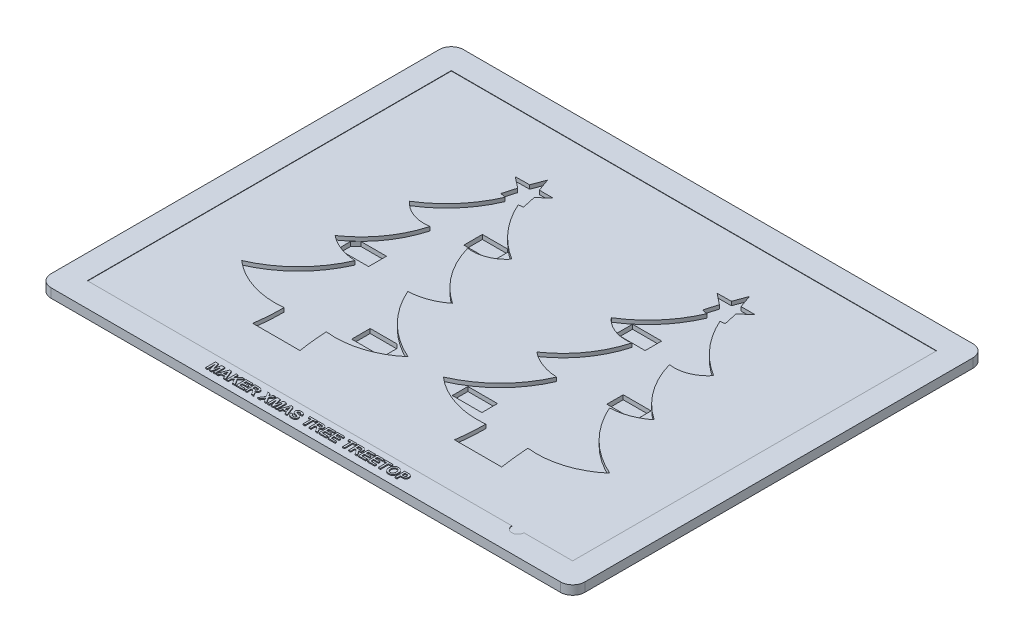
from build123d import *

# Parameters (mm, degrees)
BOSS_EXTRUDE1_DEPTH = 3.75
CUT_EXTRUDE1_DEPTH  = 0.15
BOSS_EXTRUDE2_DEPTH = 0.4
CUT_EXTRUDE3_DEPTH  = 1.6
SKETCH10_W          = 12.19588201
SKETCH10_H          = 6.447360915
SKETCH10_W_2        = 11.52373803
SKETCH10_H_2        = 6.728235922
SKETCH10_W_3        = 12.009681744
SKETCH10_H_3        = 6.810698755
CUT_EXTRUDE4_DEPTH  = 1.8


with BuildPart() as part:
    # Sketch1 → Boss-Extrude1 (new body)
    with BuildSketch(Plane(origin=(0, 0, 0), x_dir=(1, 0, 0), z_dir=(0, 1, 0))):
        with BuildLine():
            Line((-105, 85), (105, 85))
            ThreePointArc((105, 85), (108.535533906, 83.535533906), (110, 80))
            Line((110, 80), (110, -80))
            ThreePointArc((110, -80), (108.535533906, -83.535533906), (105, -85))
            Line((105, -85), (-105, -85))
            ThreePointArc((-105, -85), (-108.535533906, -83.535533906), (-110, -80))
            Line((-110, -80), (-110, 80))
            ThreePointArc((-110, 80), (-108.535533906, 83.535533906), (-105, 85))
        make_face()
    extrude(amount=BOSS_EXTRUDE1_DEPTH)

    # Sketch2 → Cut-Extrude1 (cut)
    with BuildSketch(Plane(origin=(0, 3.75, 0), x_dir=(1, 0, 0), z_dir=(0, 1, 0))):
        with BuildLine():
            Line((79.947940252, -75), (100, -75))
            Line((100, -75), (100, 75))
            Line((100, 75), (-100, 75))
            Line((-100, 75), (-100, -75))
            Line((-100, -75), (74.947940252, -75))
            ThreePointArc((74.947940252, -75), (77.447940252, -77.5), (79.947940252, -75))
        make_face()
    extrude(amount=-CUT_EXTRUDE1_DEPTH, mode=Mode.SUBTRACT)

    # Sketch5 → Boss-Extrude2 (add)
    with BuildSketch(Plane(origin=(0, 3.75, 0), x_dir=(1, 0, 0), z_dir=(0, 1, 0))):
        Polygon((-44.228593173, -82), (-44.228593173, -78), (-42.927311122, -78), (-42.254234199, -80.728365385), (-41.581157276, -78), (-40.279875224, -78), (-40.279875224, -82), (-41.049105994, -82), (-41.074747019, -78.850961538), (-41.825548301, -82), (-42.682920096, -82), (-43.433721378, -78.850961538), (-43.459362404, -82), align=None)
        Polygon((-36.074747019, -82), (-36.890452147, -82), (-37.227791891, -81.076923077), (-38.763048301, -81.076923077), (-39.100388045, -82), (-39.920900865, -82), (-38.408881635, -78), (-37.593977788, -78), align=None)
        Polygon((-37.472182917, -80.41025641), (-37.997823942, -78.974358974), (-38.521862404, -80.41025641), align=None, mode=Mode.SUBTRACT)
        Polygon((-35.664490609, -82), (-35.664490609, -78), (-34.89525984, -78), (-34.89525984, -79.790865385), (-33.208561122, -78), (-32.151670096, -78), (-33.670900865, -79.546474359), (-32.100388045, -82), (-33.125227788, -82), (-34.254234199, -80.141826923), (-34.89525984, -80.794070513), (-34.89525984, -82), align=None)
        Polygon((-31.664490609, -82), (-31.664490609, -78), (-28.690131635, -78), (-28.690131635, -78.666666667), (-30.89525984, -78.666666667), (-30.89525984, -79.538461538), (-28.843977788, -79.538461538), (-28.843977788, -80.205128205), (-30.89525984, -80.205128205), (-30.89525984, -81.333333333), (-28.638849583, -81.333333333), (-28.638849583, -82), align=None)
        with BuildLine():
            Line((-27.972182917, -82), (-27.972182917, -78))
            Line((-27.972182917, -78), (-26.293497019, -78))
            add(Edge.make_bspline(
                [(-26.293497019, -78), (-26.242480096, -78.000314416), (-26.144161146, -78.000920354), (-26.001972765, -78.005338971), (-25.87084316, -78.01459623), (-25.750190639, -78.025080153), (-25.640594706, -78.040333585), (-25.541622037, -78.058607046), (-25.453439261, -78.079783469), (-25.374759738, -78.105145668), (-25.303019997, -78.134173587), (-25.236190907, -78.168724977), (-25.173537666, -78.209206177), (-25.114097978, -78.254221912), (-25.057620142, -78.303841349), (-25.00565248, -78.359377664), (-24.957289577, -78.420003904), (-24.912570457, -78.485215655), (-24.87317571, -78.554724967), (-24.837179255, -78.626299533), (-24.807876783, -78.700701015), (-24.783673207, -78.777578925), (-24.764339018, -78.856766352), (-24.750919457, -78.938464618), (-24.742541769, -79.022525849), (-24.741793892, -79.079306772), (-24.741413686, -79.108173077)],
                knots=[0, 0, 0, 0, 0.000153053, 0.000294962, 0.000426667, 0.000547382, 0.000658208, 0.000758474, 0.000849231, 0.000930066, 0.001006251, 0.001081152, 0.001155391, 0.001229751, 0.001304678, 0.001380635, 0.001457596, 0.001537161, 0.001617565, 0.001697119, 0.001777319, 0.001857146, 0.001938771, 0.002021629, 0.002105347, 0.002191918, 0.002191918, 0.002191918, 0.002191918], degree=3))
            add(Edge.make_bspline(
                [(-24.741413686, -79.108173077), (-24.742118911, -79.144536541), (-24.743497116, -79.215600774), (-24.756180082, -79.319758822), (-24.775017527, -79.419274402), (-24.801870159, -79.514285384), (-24.838791982, -79.603674303), (-24.881653705, -79.688693371), (-24.93277351, -79.7690542), (-24.991804094, -79.843960137), (-25.058692609, -79.913477489), (-25.133732186, -79.976175641), (-25.216387067, -80.032299633), (-25.307157264, -80.08152582), (-25.405410737, -80.123608876), (-25.511573547, -80.159016277), (-25.625165094, -80.187833956), (-25.704179311, -80.201393536), (-25.744618814, -80.208333333)],
                knots=[0, 0, 0, 0, 0.000109048, 0.00021311, 0.000314313, 0.000412711, 0.000508684, 0.000604006, 0.000698033, 0.000793893, 0.000889662, 0.000986921, 0.001086709, 0.0011889, 0.001296218, 0.001406949, 0.00152433, 0.001647386, 0.001647386, 0.001647386, 0.001647386], degree=3))
            add(Edge.make_bspline(
                [(-25.744618814, -80.208333333), (-25.705509273, -80.23423595), (-25.628966574, -80.2849309), (-25.52306424, -80.368426117), (-25.427989071, -80.456060805), (-25.356002949, -80.533991022), (-25.300689034, -80.602522275), (-25.25615188, -80.662460371), (-25.208111421, -80.731440424), (-25.157038828, -80.80949981), (-25.101424265, -80.89594789), (-25.043336138, -80.992107883), (-24.981558871, -81.09704183), (-24.94002345, -81.170343505), (-24.918497019, -81.208333333)],
                knots=[0, 0, 0, 0, 0.000140684, 0.000275337, 0.000404055, 0.000528243, 0.000593191, 0.000668192, 0.000752216, 0.000845333, 0.000948026, 0.001060574, 0.001182332, 0.001313324, 0.001313324, 0.001313324, 0.001313324], degree=3))
            Line((-24.918497019, -81.208333333), (-24.433721378, -82))
            Line((-24.433721378, -82), (-25.33275984, -82))
            Line((-25.33275984, -82), (-25.901670096, -81.092147436))
            add(Edge.make_bspline(
                [(-25.901670096, -81.092147436), (-25.927797847, -81.055788596), (-25.977681094, -80.986372096), (-26.049690643, -80.887728996), (-26.11557299, -80.799918919), (-26.173574786, -80.721669989), (-26.226630895, -80.655200746), (-26.273130325, -80.599352861), (-26.312125941, -80.552927919), (-26.356249578, -80.506895587), (-26.407582745, -80.45958717), (-26.471129106, -80.413718968), (-26.536385323, -80.377153321), (-26.606302146, -80.349252873), (-26.68715884, -80.329798827), (-26.784361391, -80.317404127), (-26.900966074, -80.308259456), (-26.9852479, -80.307890941), (-27.030676506, -80.307692308)],
                knots=[0, 0, 0, 0, 0.000134319, 0.000256443, 0.00036638, 0.000463655, 0.000548625, 0.000621467, 0.000681697, 0.000730437, 0.000812688, 0.000890746, 0.000964994, 0.001036564, 0.001115854, 0.001213762, 0.001330282, 0.001466521, 0.001466521, 0.001466521, 0.001466521], degree=3))
            Line((-27.030676506, -80.307692308), (-27.202952147, -80.307692308))
            Line((-27.202952147, -80.307692308), (-27.202952147, -82))
            Line((-27.202952147, -82), (-27.972182917, -82))
        make_face()
        with BuildLine():
            Line((-27.202952147, -79.641025641), (-26.583561122, -79.641025641))
            add(Edge.make_bspline(
                [(-26.583561122, -79.641025641), (-26.535748984, -79.640923177), (-26.444658783, -79.640727965), (-26.315126705, -79.6379004), (-26.199410943, -79.635500482), (-26.098203968, -79.629470586), (-26.011052973, -79.623494391), (-25.938307564, -79.615727506), (-25.879354841, -79.606547299), (-25.820470979, -79.592274486), (-25.760153897, -79.567406928), (-25.6958673, -79.531988205), (-25.640923137, -79.486040516), (-25.593328801, -79.432920342), (-25.55702099, -79.370472745), (-25.528583387, -79.301479838), (-25.514164919, -79.224408536), (-25.511842531, -79.170988087), (-25.510644455, -79.143429487)],
                knots=[0, 0, 0, 0, 0.000143432, 0.000273262, 0.000388691, 0.000490608, 0.000577384, 0.000650739, 0.000710018, 0.000756271, 0.000832156, 0.000905007, 0.000975592, 0.001045996, 0.001117866, 0.001191221, 0.001268851, 0.001351573, 0.001351573, 0.001351573, 0.001351573], degree=3))
            add(Edge.make_bspline(
                [(-25.510644455, -79.143429487), (-25.512007041, -79.112599495), (-25.514635932, -79.053117997), (-25.535367739, -78.968475259), (-25.571554263, -78.893705053), (-25.621252095, -78.828683932), (-25.683639895, -78.77377916), (-25.757950662, -78.730196722), (-25.843632322, -78.69773833), (-25.905431468, -78.685751509), (-25.937727788, -78.679487179)],
                knots=[0, 0, 0, 0, 9.2429e-05, 0.000178327, 0.00025932, 0.000339932, 0.000422246, 0.000507034, 0.000597067, 0.000695625, 0.000695625, 0.000695625, 0.000695625], degree=3))
            add(Edge.make_bspline(
                [(-25.937727788, -78.679487179), (-25.94840337, -78.678314162), (-25.973706739, -78.675533866), (-26.018389489, -78.673748204), (-26.075522117, -78.671003446), (-26.145796158, -78.669881725), (-26.228583786, -78.667915447), (-26.324214201, -78.667554388), (-26.43238358, -78.666400832), (-26.508774334, -78.666574812), (-26.549105994, -78.666666667)],
                knots=[0, 0, 0, 0, 3.2211e-05, 7.6347e-05, 0.00013409, 0.000203819, 0.000287168, 0.000382524, 0.0004907, 0.000611694, 0.000611694, 0.000611694, 0.000611694], degree=3))
            Line((-26.549105994, -78.666666667), (-27.202952147, -78.666666667))
            Line((-27.202952147, -78.666666667), (-27.202952147, -79.641025641))
        make_face(mode=Mode.SUBTRACT)
        Polygon((-22.818336763, -82), (-21.447343173, -79.881410256), (-22.664490609, -78), (-21.765452147, -78), (-20.997823942, -79.186698718), (-20.230195737, -78), (-19.331157276, -78), (-20.548304711, -79.881410256), (-19.177311122, -82), (-20.076349583, -82), (-20.997823942, -80.576121795), (-21.919298301, -82), align=None)
        Polygon((-18.792695737, -82), (-18.792695737, -78), (-17.491413686, -78), (-16.818336763, -80.728365385), (-16.14525984, -78), (-14.843977788, -78), (-14.843977788, -82), (-15.613208558, -82), (-15.638849583, -78.850961538), (-16.389650865, -82), (-17.24702266, -82), (-17.997823942, -78.850961538), (-18.023464968, -82), align=None)
        Polygon((-10.638849583, -82), (-11.454554711, -82), (-11.791894455, -81.076923077), (-13.327150865, -81.076923077), (-13.664490609, -82), (-14.485003429, -82), (-12.972984199, -78), (-12.158080353, -78), align=None)
        Polygon((-12.036285481, -80.41025641), (-12.561926506, -78.974358974), (-13.085964968, -80.41025641), align=None, mode=Mode.SUBTRACT)
        with BuildLine():
            Line((-10.433721378, -80.666666667), (-9.664490609, -80.615384615))
            add(Edge.make_bspline(
                [(-9.664490609, -80.615384615), (-9.658362365, -80.647566522), (-9.646458641, -80.710077828), (-9.620010802, -80.799164975), (-9.590899051, -80.882219461), (-9.556108914, -80.958350668), (-9.518022599, -81.028965837), (-9.473511303, -81.092053313), (-9.425680245, -81.149627318), (-9.372161698, -81.19962004), (-9.313853935, -81.243404357), (-9.250466007, -81.280745081), (-9.182684776, -81.313064152), (-9.110344509, -81.339677882), (-9.03269963, -81.359545162), (-8.950426538, -81.373679553), (-8.86340724, -81.382730827), (-8.803936479, -81.383976916), (-8.773464968, -81.384615385)],
                knots=[0, 0, 0, 0, 9.8218e-05, 0.000190783, 0.000278478, 0.000362035, 0.000441653, 0.000518784, 0.000593269, 0.000665828, 0.000737943, 0.0008116, 0.00088615, 0.00096296, 0.001042449, 0.001126232, 0.001213218, 0.00130462, 0.00130462, 0.00130462, 0.00130462], degree=3))
            add(Edge.make_bspline(
                [(-8.773464968, -81.384615385), (-8.741391775, -81.384265468), (-8.679007762, -81.383584862), (-8.588606431, -81.375141351), (-8.504077079, -81.363045113), (-8.426166132, -81.343897052), (-8.353418676, -81.322482975), (-8.287641456, -81.293186236), (-8.227770041, -81.259396683), (-8.173958671, -81.221054296), (-8.126997439, -81.178529837), (-8.085913409, -81.134135682), (-8.050131933, -81.088830946), (-8.021969379, -81.040605206), (-7.999177802, -80.991408909), (-7.984114165, -80.939774444), (-7.973937787, -80.886887451), (-7.972770853, -80.850742796), (-7.972182917, -80.832532051)],
                knots=[0, 0, 0, 0, 9.6184e-05, 0.000187083, 0.000272188, 0.000352068, 0.000427593, 0.000499351, 0.000567531, 0.000633572, 0.000697121, 0.000757223, 0.000814921, 0.000869889, 0.0009244, 0.000977126, 0.001030878, 0.001085459, 0.001085459, 0.001085459, 0.001085459], degree=3))
            add(Edge.make_bspline(
                [(-7.972182917, -80.832532051), (-7.97290397, -80.809715465), (-7.974314605, -80.765078153), (-7.991297242, -80.701264225), (-8.016765441, -80.642142465), (-8.055111748, -80.588586101), (-8.106658623, -80.53964339), (-8.172411798, -80.493858682), (-8.254206672, -80.452670351), (-8.314887828, -80.429695424), (-8.347182917, -80.417467949)],
                knots=[0, 0, 0, 0, 6.8278e-05, 0.000133577, 0.00019671, 0.000260517, 0.00032965, 0.000409014, 0.00050004, 0.0006036, 0.0006036, 0.0006036, 0.0006036], degree=3))
            add(Edge.make_bspline(
                [(-8.347182917, -80.417467949), (-8.361039884, -80.412824415), (-8.392049526, -80.402432941), (-8.444948684, -80.387574113), (-8.508667124, -80.369019384), (-8.584125619, -80.347928973), (-8.671298796, -80.326359034), (-8.769213045, -80.299787317), (-8.87906205, -80.273346287), (-8.955912545, -80.253827525), (-8.996221378, -80.243589744)],
                knots=[0, 0, 0, 0, 4.3837e-05, 9.81e-05, 0.000164799, 0.000242947, 0.000333123, 0.000434186, 0.000547292, 0.000672058, 0.000672058, 0.000672058, 0.000672058], degree=3))
            add(Edge.make_bspline(
                [(-8.996221378, -80.243589744), (-9.048715442, -80.230483201), (-9.149994155, -80.20519627), (-9.294440791, -80.160212611), (-9.427478785, -80.115518856), (-9.547827196, -80.067023734), (-9.656813516, -80.018013888), (-9.75267486, -79.965048504), (-9.837411644, -79.910878263), (-9.886789734, -79.870390101), (-9.910484199, -79.850961538)],
                knots=[0, 0, 0, 0, 0.000162281, 0.000313094, 0.00045373, 0.000583181, 0.000702217, 0.000811955, 0.00091152, 0.001003374, 0.001003374, 0.001003374, 0.001003374], degree=3))
            add(Edge.make_bspline(
                [(-9.910484199, -79.850961538), (-9.939868415, -79.823449223), (-9.997478887, -79.769508786), (-10.073314133, -79.680874294), (-10.137036389, -79.587246136), (-10.189486782, -79.48931541), (-10.229872592, -79.386518334), (-10.258497535, -79.27954299), (-10.277024639, -79.168110183), (-10.278915202, -79.092221801), (-10.279875224, -79.053685897)],
                knots=[0, 0, 0, 0, 0.000120696, 0.000236636, 0.000349093, 0.000459858, 0.000569223, 0.000679629, 0.000791602, 0.000907123, 0.000907123, 0.000907123, 0.000907123], degree=3))
            add(Edge.make_bspline(
                [(-10.279875224, -79.053685897), (-10.278005573, -79.003820898), (-10.274296742, -78.904903623), (-10.240284345, -78.759508732), (-10.187302326, -78.61921386), (-10.125855746, -78.507814536), (-10.06681884, -78.423540527), (-10.017792988, -78.363066269), (-9.963933352, -78.306468177), (-9.904502171, -78.255126858), (-9.841706271, -78.206034956), (-9.773112698, -78.16244076), (-9.700666286, -78.121377439), (-9.595828075, -78.072698782), (-9.453486551, -78.02197084), (-9.268292582, -77.979210404), (-9.066653021, -77.953505859), (-8.926855692, -77.950352455), (-8.854394455, -77.948717949)],
                knots=[0, 0, 0, 0, 0.000149402, 0.000296369, 0.000445485, 0.000598261, 0.000676508, 0.000753972, 0.000831614, 0.000910535, 0.000989387, 0.001070511, 0.001154098, 0.001239053, 0.001416977, 0.001606283, 0.001808238, 0.002025564, 0.002025564, 0.002025564, 0.002025564], degree=3))
            add(Edge.make_bspline(
                [(-8.854394455, -77.948717949), (-8.795063132, -77.949511357), (-8.679664979, -77.95105452), (-8.51238195, -77.966659226), (-8.356130525, -77.990946107), (-8.211459008, -78.02580981), (-8.078299993, -78.071873913), (-7.956137316, -78.126744969), (-7.845074785, -78.191890681), (-7.746464478, -78.267684898), (-7.658612147, -78.351243161), (-7.581975037, -78.442513034), (-7.516260151, -78.540341837), (-7.461043373, -78.644658076), (-7.417681782, -78.755998089), (-7.385834406, -78.874222945), (-7.364770275, -78.999054373), (-7.359490486, -79.084590115), (-7.356798301, -79.128205128)],
                knots=[0, 0, 0, 0, 0.00017795, 0.000346108, 0.000503529, 0.000652006, 0.000791885, 0.000925641, 0.001053168, 0.001177212, 0.001297929, 0.001416221, 0.001534007, 0.001650854, 0.001769595, 0.001891666, 0.0020176, 0.002148624, 0.002148624, 0.002148624, 0.002148624], degree=3))
            Line((-7.356798301, -79.128205128), (-8.12602907, -79.179487179))
            add(Edge.make_bspline(
                [(-8.12602907, -79.179487179), (-8.130466568, -79.155366166), (-8.139114791, -79.108356818), (-8.157918394, -79.041029882), (-8.179127946, -78.978760145), (-8.203952628, -78.921548007), (-8.233937845, -78.870418192), (-8.266570377, -78.823762129), (-8.302750408, -78.782201483), (-8.343675874, -78.746874318), (-8.387940399, -78.714728047), (-8.438386356, -78.688962066), (-8.492900007, -78.665056907), (-8.553555263, -78.64708609), (-8.619187324, -78.632830992), (-8.68983442, -78.622263189), (-8.765642992, -78.617103393), (-8.817796495, -78.615970657), (-8.84477907, -78.615384615)],
                knots=[0, 0, 0, 0, 7.3544e-05, 0.000143329, 0.000209467, 0.000270811, 0.000330046, 0.00038696, 0.000441459, 0.000494827, 0.000548853, 0.000605131, 0.000664366, 0.000727225, 0.000794494, 0.000865772, 0.000941301, 0.001022267, 0.001022267, 0.001022267, 0.001022267], degree=3))
            add(Edge.make_bspline(
                [(-8.84477907, -78.615384615), (-8.87283358, -78.615901994), (-8.927414881, -78.616908577), (-9.006954385, -78.623085828), (-9.081568407, -78.634488439), (-9.151623398, -78.64933181), (-9.217025781, -78.66952519), (-9.277637537, -78.694147708), (-9.33373597, -78.723135992), (-9.367942348, -78.745942974), (-9.384843173, -78.757211538)],
                knots=[0, 0, 0, 0, 8.4169e-05, 0.000163754, 0.000239113, 0.000310468, 0.000378393, 0.000444161, 0.000506523, 0.000567425, 0.000567425, 0.000567425, 0.000567425], degree=3))
            add(Edge.make_bspline(
                [(-9.384843173, -78.757211538), (-9.404184748, -78.772604718), (-9.441643374, -78.802416529), (-9.481956783, -78.86161265), (-9.506225548, -78.928472893), (-9.509146569, -78.975754314), (-9.510644455, -79)],
                knots=[0, 0, 0, 0, 7.3796e-05, 0.000142921, 0.000211859, 0.000284418, 0.000284418, 0.000284418, 0.000284418], degree=3))
            add(Edge.make_bspline(
                [(-9.510644455, -79), (-9.509419458, -79.022659203), (-9.507006408, -79.067294227), (-9.482667692, -79.130699244), (-9.445238064, -79.189448553), (-9.410266215, -79.221361948), (-9.392054711, -79.237980769)],
                knots=[0, 0, 0, 0, 6.7693e-05, 0.000133344, 0.000201132, 0.000274789, 0.000274789, 0.000274789, 0.000274789], degree=3))
            add(Edge.make_bspline(
                [(-9.392054711, -79.237980769), (-9.377601537, -79.248767218), (-9.345304707, -79.272870441), (-9.286143318, -79.303507918), (-9.214733968, -79.336690157), (-9.129448697, -79.369129458), (-9.030854309, -79.401508544), (-8.918944809, -79.435316053), (-8.793651366, -79.469577459), (-8.65816765, -79.502757953), (-8.52061352, -79.535372472), (-8.389349403, -79.571029347), (-8.267292651, -79.605792043), (-8.155009206, -79.642228989), (-8.051920268, -79.677700243), (-7.958526606, -79.714131775), (-7.874186943, -79.749612011), (-7.775837546, -79.798399849), (-7.664368396, -79.864484947), (-7.547536152, -79.960550658), (-7.444212941, -80.068534792), (-7.372220074, -80.170356382), (-7.322764741, -80.257925658), (-7.290920725, -80.327728568), (-7.263373153, -80.401283234), (-7.240949505, -80.47867094), (-7.224697755, -80.560000579), (-7.211248487, -80.644650792), (-7.204377006, -80.733324619), (-7.203432212, -80.793793859), (-7.202952147, -80.824519231)],
                knots=[0, 0, 0, 0, 5.4026e-05, 0.000120725, 0.000199242, 0.00029031, 0.000394199, 0.000510551, 0.000640985, 0.000783825, 0.000928999, 0.001065056, 0.001191851, 0.001309683, 0.001419157, 0.001518855, 0.001610391, 0.001693527, 0.001848125, 0.001997922, 0.002145856, 0.002295264, 0.002370602, 0.002447328, 0.002525168, 0.002606066, 0.002688726, 0.002773832, 0.002863066, 0.002955245, 0.002955245, 0.002955245, 0.002955245], degree=3))
            add(Edge.make_bspline(
                [(-7.202952147, -80.824519231), (-7.203612252, -80.852854893), (-7.204923155, -80.909126773), (-7.214084102, -80.992648449), (-7.228251276, -81.074686934), (-7.249223562, -81.155345075), (-7.277045438, -81.234464198), (-7.308370661, -81.313186212), (-7.347541088, -81.389794355), (-7.392122377, -81.464352078), (-7.441297564, -81.53680343), (-7.497022184, -81.603638152), (-7.556023192, -81.667086011), (-7.622070594, -81.723594281), (-7.691085816, -81.777738468), (-7.766225542, -81.825689471), (-7.845729358, -81.869080883), (-7.930099952, -81.907588743), (-8.019636466, -81.941144863), (-8.114222609, -81.971012143), (-8.214710546, -81.995456217), (-8.320262351, -82.016407868), (-8.431264297, -82.032341057), (-8.547577606, -82.043466128), (-8.669228721, -82.049739997), (-8.752090456, -82.050761647), (-8.794298301, -82.051282051)],
                knots=[0, 0, 0, 0, 8.4996e-05, 0.000168795, 0.000251788, 0.00033458, 0.000418455, 0.00050327, 0.000588557, 0.00067623, 0.000763801, 0.000850905, 0.000937057, 0.001023365, 0.001111353, 0.001200035, 0.001290396, 0.001382905, 0.001478001, 0.001577092, 0.001680286, 0.001788087, 0.00189982, 0.002016546, 0.002138509, 0.002265135, 0.002265135, 0.002265135, 0.002265135], degree=3))
            add(Edge.make_bspline(
                [(-8.794298301, -82.051282051), (-8.855239918, -82.050287076), (-8.973894691, -82.048349835), (-9.146278765, -82.031010004), (-9.307963616, -82.004470143), (-9.45868603, -81.965951852), (-9.59863023, -81.91650306), (-9.727732386, -81.855593067), (-9.845368047, -81.782857968), (-9.952994194, -81.700061712), (-10.049176876, -81.605695542), (-10.135664538, -81.50171469), (-10.211290437, -81.387182825), (-10.276004863, -81.262279091), (-10.33144391, -81.127678715), (-10.377165025, -80.983319892), (-10.411590622, -80.828514106), (-10.426216876, -80.721548863), (-10.433721378, -80.666666667)],
                knots=[0, 0, 0, 0, 0.000182778, 0.000355874, 0.000519219, 0.000673917, 0.000821926, 0.00096386, 0.001101288, 0.00123608, 0.001370373, 0.001504668, 0.001641122, 0.001781257, 0.001926043, 0.002077333, 0.00223499, 0.00240112, 0.00240112, 0.00240112, 0.00240112], degree=3))
        make_face()
        Polygon((-4.074747019, -82), (-4.074747019, -78.666666667), (-5.254234199, -78.666666667), (-5.254234199, -78), (-2.12602907, -78), (-2.12602907, -78.666666667), (-3.30551625, -78.666666667), (-3.30551625, -82), align=None)
        with BuildLine():
            Line((-1.613208558, -82), (-1.613208558, -78))
            Line((-1.613208558, -78), (0.06547734, -78))
            add(Edge.make_bspline(
                [(0.06547734, -78), (0.116494263, -78.000314416), (0.214813213, -78.000920354), (0.357001594, -78.005338971), (0.488131199, -78.01459623), (0.60878372, -78.025080153), (0.718379653, -78.040333585), (0.817352322, -78.058607046), (0.905535098, -78.079783469), (0.984214621, -78.105145668), (1.055954362, -78.134173587), (1.122783452, -78.168724977), (1.185436693, -78.209206177), (1.244876381, -78.254221912), (1.301354217, -78.303841349), (1.353321879, -78.359377664), (1.401684782, -78.420003904), (1.446403902, -78.485215655), (1.485798649, -78.554724967), (1.521795104, -78.626299533), (1.551097576, -78.700701015), (1.575301152, -78.777578925), (1.594635341, -78.856766352), (1.608054902, -78.938464618), (1.61643259, -79.022525849), (1.617180467, -79.079306772), (1.617560673, -79.108173077)],
                knots=[0, 0, 0, 0, 0.000153053, 0.000294962, 0.000426667, 0.000547382, 0.000658208, 0.000758474, 0.000849231, 0.000930066, 0.001006251, 0.001081152, 0.001155391, 0.001229751, 0.001304678, 0.001380635, 0.001457596, 0.001537161, 0.001617565, 0.001697119, 0.001777319, 0.001857146, 0.001938771, 0.002021629, 0.002105347, 0.002191918, 0.002191918, 0.002191918, 0.002191918], degree=3))
            add(Edge.make_bspline(
                [(1.617560673, -79.108173077), (1.616855448, -79.144536541), (1.615477243, -79.215600774), (1.602794277, -79.319758822), (1.583956832, -79.419274402), (1.5571042, -79.514285384), (1.520182377, -79.603674303), (1.477320654, -79.688693371), (1.426200849, -79.7690542), (1.367170265, -79.843960137), (1.30028175, -79.913477489), (1.225242173, -79.976175641), (1.142587292, -80.032299633), (1.051817095, -80.08152582), (0.953563622, -80.123608876), (0.847400812, -80.159016277), (0.733809265, -80.187833956), (0.654795048, -80.201393536), (0.614355545, -80.208333333)],
                knots=[0, 0, 0, 0, 0.000109048, 0.00021311, 0.000314313, 0.000412711, 0.000508684, 0.000604006, 0.000698033, 0.000793893, 0.000889662, 0.000986921, 0.001086709, 0.0011889, 0.001296218, 0.001406949, 0.00152433, 0.001647386, 0.001647386, 0.001647386, 0.001647386], degree=3))
            add(Edge.make_bspline(
                [(0.614355545, -80.208333333), (0.653465086, -80.23423595), (0.730007785, -80.2849309), (0.835910119, -80.368426117), (0.930985288, -80.456060805), (1.00297141, -80.533991022), (1.058285325, -80.602522275), (1.102822479, -80.662460371), (1.150862938, -80.731440424), (1.201935531, -80.80949981), (1.257550094, -80.89594789), (1.315638221, -80.992107883), (1.377415488, -81.09704183), (1.418950909, -81.170343505), (1.44047734, -81.208333333)],
                knots=[0, 0, 0, 0, 0.000140684, 0.000275337, 0.000404055, 0.000528243, 0.000593191, 0.000668192, 0.000752216, 0.000845333, 0.000948026, 0.001060574, 0.001182332, 0.001313324, 0.001313324, 0.001313324, 0.001313324], degree=3))
            Line((1.44047734, -81.208333333), (1.925252981, -82))
            Line((1.925252981, -82), (1.026214519, -82))
            Line((1.026214519, -82), (0.457304263, -81.092147436))
            add(Edge.make_bspline(
                [(0.457304263, -81.092147436), (0.431176512, -81.055788596), (0.381293265, -80.986372096), (0.309283716, -80.887728996), (0.243401369, -80.799918919), (0.185399573, -80.721669989), (0.132343464, -80.655200746), (0.085844034, -80.599352861), (0.046848417, -80.552927919), (0.002724781, -80.506895587), (-0.048608386, -80.45958717), (-0.112154747, -80.413718968), (-0.177410964, -80.377153321), (-0.247327787, -80.349252873), (-0.328184481, -80.329798827), (-0.425387032, -80.317404127), (-0.541991715, -80.308259456), (-0.626273541, -80.307890941), (-0.671702147, -80.307692308)],
                knots=[0, 0, 0, 0, 0.000134319, 0.000256443, 0.00036638, 0.000463655, 0.000548625, 0.000621467, 0.000681697, 0.000730437, 0.000812688, 0.000890746, 0.000964994, 0.001036564, 0.001115854, 0.001213762, 0.001330282, 0.001466521, 0.001466521, 0.001466521, 0.001466521], degree=3))
            Line((-0.671702147, -80.307692308), (-0.843977788, -80.307692308))
            Line((-0.843977788, -80.307692308), (-0.843977788, -82))
            Line((-0.843977788, -82), (-1.613208558, -82))
        make_face()
        with BuildLine():
            Line((-0.843977788, -79.641025641), (-0.224586763, -79.641025641))
            add(Edge.make_bspline(
                [(-0.224586763, -79.641025641), (-0.176774625, -79.640923177), (-0.085684424, -79.640727965), (0.043847654, -79.6379004), (0.159563416, -79.635500482), (0.260770391, -79.629470586), (0.347921386, -79.623494391), (0.420666795, -79.615727506), (0.479619518, -79.606547299), (0.53850338, -79.592274486), (0.598820462, -79.567406928), (0.663107059, -79.531988205), (0.718051222, -79.486040516), (0.765645558, -79.432920342), (0.801953369, -79.370472745), (0.830390972, -79.301479838), (0.84480944, -79.224408536), (0.847131828, -79.170988087), (0.848329904, -79.143429487)],
                knots=[0, 0, 0, 0, 0.000143432, 0.000273262, 0.000388691, 0.000490608, 0.000577384, 0.000650739, 0.000710018, 0.000756271, 0.000832156, 0.000905007, 0.000975592, 0.001045996, 0.001117866, 0.001191221, 0.001268851, 0.001351573, 0.001351573, 0.001351573, 0.001351573], degree=3))
            add(Edge.make_bspline(
                [(0.848329904, -79.143429487), (0.846967318, -79.112599495), (0.844338427, -79.053117997), (0.82360662, -78.968475259), (0.787420096, -78.893705053), (0.737722264, -78.828683932), (0.675334464, -78.77377916), (0.601023697, -78.730196722), (0.515342037, -78.69773833), (0.453542891, -78.685751509), (0.421246571, -78.679487179)],
                knots=[0, 0, 0, 0, 9.2429e-05, 0.000178327, 0.00025932, 0.000339932, 0.000422246, 0.000507034, 0.000597067, 0.000695625, 0.000695625, 0.000695625, 0.000695625], degree=3))
            add(Edge.make_bspline(
                [(0.421246571, -78.679487179), (0.410570989, -78.678314162), (0.38526762, -78.675533866), (0.34058487, -78.673748204), (0.283452242, -78.671003446), (0.213178201, -78.669881725), (0.130390573, -78.667915447), (0.034760158, -78.667554388), (-0.073409221, -78.666400832), (-0.149799975, -78.666574812), (-0.190131635, -78.666666667)],
                knots=[0, 0, 0, 0, 3.2211e-05, 7.6347e-05, 0.00013409, 0.000203819, 0.000287168, 0.000382524, 0.0004907, 0.000611694, 0.000611694, 0.000611694, 0.000611694], degree=3))
            Line((-0.190131635, -78.666666667), (-0.843977788, -78.666666667))
            Line((-0.843977788, -78.666666667), (-0.843977788, -79.641025641))
        make_face(mode=Mode.SUBTRACT)
        Polygon((2.386791442, -82), (2.386791442, -78), (5.361150417, -78), (5.361150417, -78.666666667), (3.156022212, -78.666666667), (3.156022212, -79.538461538), (5.207304263, -79.538461538), (5.207304263, -80.205128205), (3.156022212, -80.205128205), (3.156022212, -81.333333333), (5.412432468, -81.333333333), (5.412432468, -82), align=None)
        Polygon((6.079099135, -82), (6.079099135, -78), (9.053458109, -78), (9.053458109, -78.666666667), (6.848329904, -78.666666667), (6.848329904, -79.538461538), (8.899611955, -79.538461538), (8.899611955, -80.205128205), (6.848329904, -80.205128205), (6.848329904, -81.333333333), (9.10474016, -81.333333333), (9.10474016, -82), align=None)
        Polygon((12.232945289, -82), (12.232945289, -78.666666667), (11.053458109, -78.666666667), (11.053458109, -78), (14.181663237, -78), (14.181663237, -78.666666667), (13.002176058, -78.666666667), (13.002176058, -82), align=None)
        with BuildLine():
            Line((14.69448375, -82), (14.69448375, -78))
            Line((14.69448375, -78), (16.373169647, -78))
            add(Edge.make_bspline(
                [(16.373169647, -78), (16.424186571, -78.000314416), (16.52250552, -78.000920354), (16.664693902, -78.005338971), (16.795823507, -78.01459623), (16.916476028, -78.025080153), (17.026071961, -78.040333585), (17.125044629, -78.058607046), (17.213227406, -78.079783469), (17.291906929, -78.105145668), (17.36364667, -78.134173587), (17.430475759, -78.168724977), (17.493129001, -78.209206177), (17.552568689, -78.254221912), (17.609046525, -78.303841349), (17.661014187, -78.359377664), (17.709377089, -78.420003904), (17.75409621, -78.485215655), (17.793490956, -78.554724967), (17.829487411, -78.626299533), (17.858789884, -78.700701015), (17.882993459, -78.777578925), (17.902327649, -78.856766352), (17.91574721, -78.938464618), (17.924124898, -79.022525849), (17.924872775, -79.079306772), (17.925252981, -79.108173077)],
                knots=[0, 0, 0, 0, 0.000153053, 0.000294962, 0.000426667, 0.000547382, 0.000658208, 0.000758474, 0.000849231, 0.000930066, 0.001006251, 0.001081152, 0.001155391, 0.001229751, 0.001304678, 0.001380635, 0.001457596, 0.001537161, 0.001617565, 0.001697119, 0.001777319, 0.001857146, 0.001938771, 0.002021629, 0.002105347, 0.002191918, 0.002191918, 0.002191918, 0.002191918], degree=3))
            add(Edge.make_bspline(
                [(17.925252981, -79.108173077), (17.924547756, -79.144536541), (17.923169551, -79.215600774), (17.910486584, -79.319758822), (17.89164914, -79.419274402), (17.864796508, -79.514285384), (17.827874685, -79.603674303), (17.785012962, -79.688693371), (17.733893157, -79.7690542), (17.674862573, -79.843960137), (17.607974058, -79.913477489), (17.53293448, -79.976175641), (17.450279599, -80.032299633), (17.359509403, -80.08152582), (17.26125593, -80.123608876), (17.15509312, -80.159016277), (17.041501573, -80.187833956), (16.962487355, -80.201393536), (16.922047853, -80.208333333)],
                knots=[0, 0, 0, 0, 0.000109048, 0.00021311, 0.000314313, 0.000412711, 0.000508684, 0.000604006, 0.000698033, 0.000793893, 0.000889662, 0.000986921, 0.001086709, 0.0011889, 0.001296218, 0.001406949, 0.00152433, 0.001647386, 0.001647386, 0.001647386, 0.001647386], degree=3))
            add(Edge.make_bspline(
                [(16.922047853, -80.208333333), (16.961157393, -80.23423595), (17.037700092, -80.2849309), (17.143602427, -80.368426117), (17.238677595, -80.456060805), (17.310663717, -80.533991022), (17.365977633, -80.602522275), (17.410514786, -80.662460371), (17.458555245, -80.731440424), (17.509627839, -80.80949981), (17.565242402, -80.89594789), (17.623330529, -80.992107883), (17.685107796, -81.09704183), (17.726643216, -81.170343505), (17.748169647, -81.208333333)],
                knots=[0, 0, 0, 0, 0.000140684, 0.000275337, 0.000404055, 0.000528243, 0.000593191, 0.000668192, 0.000752216, 0.000845333, 0.000948026, 0.001060574, 0.001182332, 0.001313324, 0.001313324, 0.001313324, 0.001313324], degree=3))
            Line((17.748169647, -81.208333333), (18.232945289, -82))
            Line((18.232945289, -82), (17.333906827, -82))
            Line((17.333906827, -82), (16.764996571, -81.092147436))
            add(Edge.make_bspline(
                [(16.764996571, -81.092147436), (16.73886882, -81.055788596), (16.688985573, -80.986372096), (16.616976023, -80.887728996), (16.551093676, -80.799918919), (16.493091881, -80.721669989), (16.440035771, -80.655200746), (16.393536342, -80.599352861), (16.354540725, -80.552927919), (16.310417088, -80.506895587), (16.259083921, -80.45958717), (16.195537561, -80.413718968), (16.130281344, -80.377153321), (16.060364521, -80.349252873), (15.979507827, -80.329798827), (15.882305275, -80.317404127), (15.765700592, -80.308259456), (15.681418767, -80.307890941), (15.63599016, -80.307692308)],
                knots=[0, 0, 0, 0, 0.000134319, 0.000256443, 0.00036638, 0.000463655, 0.000548625, 0.000621467, 0.000681697, 0.000730437, 0.000812688, 0.000890746, 0.000964994, 0.001036564, 0.001115854, 0.001213762, 0.001330282, 0.001466521, 0.001466521, 0.001466521, 0.001466521], degree=3))
            Line((15.63599016, -80.307692308), (15.463714519, -80.307692308))
            Line((15.463714519, -80.307692308), (15.463714519, -82))
            Line((15.463714519, -82), (14.69448375, -82))
        make_face()
        with BuildLine():
            Line((15.463714519, -79.641025641), (16.083105545, -79.641025641))
            add(Edge.make_bspline(
                [(16.083105545, -79.641025641), (16.130917682, -79.640923177), (16.222007884, -79.640727965), (16.351539962, -79.6379004), (16.467255724, -79.635500482), (16.568462698, -79.629470586), (16.655613694, -79.623494391), (16.728359103, -79.615727506), (16.787311826, -79.606547299), (16.846195688, -79.592274486), (16.90651277, -79.567406928), (16.970799367, -79.531988205), (17.02574353, -79.486040516), (17.073337866, -79.432920342), (17.109645677, -79.370472745), (17.13808328, -79.301479838), (17.152501747, -79.224408536), (17.154824135, -79.170988087), (17.156022212, -79.143429487)],
                knots=[0, 0, 0, 0, 0.000143432, 0.000273262, 0.000388691, 0.000490608, 0.000577384, 0.000650739, 0.000710018, 0.000756271, 0.000832156, 0.000905007, 0.000975592, 0.001045996, 0.001117866, 0.001191221, 0.001268851, 0.001351573, 0.001351573, 0.001351573, 0.001351573], degree=3))
            add(Edge.make_bspline(
                [(17.156022212, -79.143429487), (17.154659625, -79.112599495), (17.152030734, -79.053117997), (17.131298928, -78.968475259), (17.095112404, -78.893705053), (17.045414571, -78.828683932), (16.983026772, -78.77377916), (16.908716005, -78.730196722), (16.823034344, -78.69773833), (16.761235198, -78.685751509), (16.728938878, -78.679487179)],
                knots=[0, 0, 0, 0, 9.2429e-05, 0.000178327, 0.00025932, 0.000339932, 0.000422246, 0.000507034, 0.000597067, 0.000695625, 0.000695625, 0.000695625, 0.000695625], degree=3))
            add(Edge.make_bspline(
                [(16.728938878, -78.679487179), (16.718263297, -78.678314162), (16.692959928, -78.675533866), (16.648277178, -78.673748204), (16.591144549, -78.671003446), (16.520870509, -78.669881725), (16.438082881, -78.667915447), (16.342452465, -78.667554388), (16.234283087, -78.666400832), (16.157892332, -78.666574812), (16.117560673, -78.666666667)],
                knots=[0, 0, 0, 0, 3.2211e-05, 7.6347e-05, 0.00013409, 0.000203819, 0.000287168, 0.000382524, 0.0004907, 0.000611694, 0.000611694, 0.000611694, 0.000611694], degree=3))
            Line((16.117560673, -78.666666667), (15.463714519, -78.666666667))
            Line((15.463714519, -78.666666667), (15.463714519, -79.641025641))
        make_face(mode=Mode.SUBTRACT)
        Polygon((18.69448375, -82), (18.69448375, -78), (21.668842724, -78), (21.668842724, -78.666666667), (19.463714519, -78.666666667), (19.463714519, -79.538461538), (21.514996571, -79.538461538), (21.514996571, -80.205128205), (19.463714519, -80.205128205), (19.463714519, -81.333333333), (21.720124776, -81.333333333), (21.720124776, -82), align=None)
        Polygon((22.386791442, -82), (22.386791442, -78), (25.361150417, -78), (25.361150417, -78.666666667), (23.156022212, -78.666666667), (23.156022212, -79.538461538), (25.207304263, -79.538461538), (25.207304263, -80.205128205), (23.156022212, -80.205128205), (23.156022212, -81.333333333), (25.412432468, -81.333333333), (25.412432468, -82), align=None)
        Polygon((27.002176058, -82), (27.002176058, -78.666666667), (25.822688878, -78.666666667), (25.822688878, -78), (28.950894006, -78), (28.950894006, -78.666666667), (27.771406827, -78.666666667), (27.771406827, -82), align=None)
        with BuildLine():
            add(Edge.make_bspline(
                [(29.309868365, -80.024038462), (29.310151429, -79.974608112), (29.31070733, -79.877533287), (29.320339795, -79.735120874), (29.333036135, -79.598613259), (29.353712104, -79.468547376), (29.378034592, -79.344314473), (29.408455569, -79.225951427), (29.445102074, -79.113873332), (29.474254659, -79.04231268), (29.488554263, -79.007211538)],
                knots=[0, 0, 0, 0, 0.000148257, 0.000291157, 0.000428054, 0.000559399, 0.000686057, 0.000807717, 0.000925797, 0.001039477, 0.001039477, 0.001039477, 0.001039477], degree=3))
            add(Edge.make_bspline(
                [(29.488554263, -79.007211538), (29.511928689, -78.957311201), (29.558402619, -78.858097434), (29.644712012, -78.717900407), (29.74253862, -78.58568325), (29.851077063, -78.462139102), (29.967556321, -78.349127849), (30.092525888, -78.252406489), (30.221545972, -78.168708535), (30.313308542, -78.12661344), (30.358746571, -78.105769231)],
                knots=[0, 0, 0, 0, 0.0001652, 0.000328457, 0.000492884, 0.000658114, 0.000821327, 0.000978889, 0.001131606, 0.001281401, 0.001281401, 0.001281401, 0.001281401], degree=3))
            add(Edge.make_bspline(
                [(30.358746571, -78.105769231), (30.389589734, -78.093118053), (30.451931632, -78.067546798), (30.54881828, -78.035632531), (30.649381082, -78.009703632), (30.752892672, -77.986526217), (30.860358062, -77.970544626), (30.970908888, -77.957144612), (31.085150156, -77.950121432), (31.162424397, -77.949190865), (31.201695289, -77.948717949)],
                knots=[0, 0, 0, 0, 9.999e-05, 0.000202106, 0.000305698, 0.00041147, 0.000520152, 0.00063147, 0.00074548, 0.000863293, 0.000863293, 0.000863293, 0.000863293], degree=3))
            add(Edge.make_bspline(
                [(31.201695289, -77.948717949), (31.27201286, -77.950480579), (31.409625314, -77.953930072), (31.610638466, -77.978845345), (31.800857941, -78.020917077), (31.979639841, -78.081726325), (32.14852557, -78.157739204), (32.306202985, -78.252024525), (32.452905453, -78.363561831), (32.588349625, -78.49082159), (32.710326803, -78.633582017), (32.816558792, -78.790509519), (32.905673069, -78.960868719), (32.979063821, -79.144189587), (33.035459083, -79.341070908), (33.076204608, -79.550957161), (33.100410748, -79.774002945), (33.103271138, -79.927022232), (33.10474016, -80.005608974)],
                knots=[0, 0, 0, 0, 0.000210921, 0.000412776, 0.000606589, 0.00079435, 0.000978307, 0.001161212, 0.001344227, 0.001530156, 0.001717711, 0.001906393, 0.002097431, 0.002293394, 0.002497785, 0.002710875, 0.002934128, 0.003169841, 0.003169841, 0.003169841, 0.003169841], degree=3))
            add(Edge.make_bspline(
                [(33.10474016, -80.005608974), (33.103305068, -80.083669488), (33.100511212, -80.235638725), (33.075853249, -80.456934259), (33.036796974, -80.665290436), (32.97903717, -80.860231293), (32.907836824, -81.043244361), (32.81780554, -81.212149806), (32.713798369, -81.36918805), (32.591994437, -81.510410123), (32.458829867, -81.638400225), (32.312313484, -81.748633941), (32.155783883, -81.843047013), (31.987818951, -81.919279558), (31.809513452, -81.97883646), (31.6202855, -82.021231483), (31.420038043, -82.046050879), (31.28296177, -82.049512896), (31.212913237, -82.051282051)],
                knots=[0, 0, 0, 0, 0.000234112, 0.000455771, 0.000667135, 0.000869219, 0.001064884, 0.001255214, 0.001442337, 0.001628762, 0.001813526, 0.001995419, 0.002177636, 0.002360864, 0.002547611, 0.002740642, 0.002941701, 0.003151822, 0.003151822, 0.003151822, 0.003151822], degree=3))
            add(Edge.make_bspline(
                [(31.212913237, -82.051282051), (31.142064566, -82.049508814), (31.003393364, -82.046038078), (30.801010081, -82.02129423), (30.609903719, -81.978885252), (30.430210363, -81.919118857), (30.260704471, -81.844044378), (30.102951025, -81.750596071), (29.956862824, -81.639664224), (29.822585587, -81.513180678), (29.70085697, -81.372373801), (29.596997476, -81.216345269), (29.506961496, -81.049089607), (29.435386814, -80.868073293), (29.377945073, -80.675158752), (29.33879336, -80.469235937), (29.314087717, -80.250871605), (29.311300523, -80.101031531), (29.309868365, -80.024038462)],
                knots=[0, 0, 0, 0, 0.000212523, 0.000415968, 0.000610562, 0.000798829, 0.000983187, 0.001165682, 0.001347575, 0.001532371, 0.001718187, 0.001904645, 0.002093559, 0.002286992, 0.002487538, 0.002696542, 0.002915016, 0.003145925, 0.003145925, 0.003145925, 0.003145925], degree=3))
        make_face()
        with BuildLine():
            add(Edge.make_bspline(
                [(30.079099135, -79.997596154), (30.079867587, -80.052926721), (30.081355679, -80.160073313), (30.097205835, -80.315593997), (30.121259721, -80.460984026), (30.156634494, -80.596078385), (30.201323787, -80.720974806), (30.256077435, -80.835777762), (30.320669162, -80.940658241), (30.396769638, -81.033402068), (30.479104386, -81.116204428), (30.567977402, -81.187849353), (30.661732404, -81.249514577), (30.761991639, -81.298199063), (30.866668533, -81.336835528), (30.976576352, -81.365483053), (31.092261584, -81.381213357), (31.171201975, -81.383469211), (31.211310673, -81.384615385)],
                knots=[0, 0, 0, 0, 0.000165935, 0.00032133, 0.000468474, 0.00060763, 0.000739686, 0.000865841, 0.000988573, 0.001108209, 0.001224927, 0.001338305, 0.001450097, 0.001560828, 0.001671868, 0.001784394, 0.001900886, 0.002021209, 0.002021209, 0.002021209, 0.002021209], degree=3))
            add(Edge.make_bspline(
                [(31.211310673, -81.384615385), (31.251424775, -81.383492434), (31.330375801, -81.381282287), (31.445918891, -81.365230356), (31.556044518, -81.337810725), (31.660305561, -81.299372249), (31.759177228, -81.249914713), (31.852573401, -81.189631894), (31.939955721, -81.117661016), (32.022200849, -81.036061566), (32.096247191, -80.942701745), (32.160288972, -80.837839365), (32.215015643, -80.722340126), (32.259709642, -80.596160819), (32.294213834, -80.459064039), (32.317286023, -80.310977248), (32.33326435, -80.152323872), (32.334746373, -80.042777837), (32.335509391, -79.986378205)],
                knots=[0, 0, 0, 0, 0.000120323, 0.000236815, 0.000349144, 0.000460184, 0.000569479, 0.000680163, 0.000792919, 0.000908504, 0.001027137, 0.001149448, 0.001276326, 0.001409891, 0.001550399, 0.001699781, 0.001859164, 0.002028303, 0.002028303, 0.002028303, 0.002028303], degree=3))
            add(Edge.make_bspline(
                [(32.335509391, -79.986378205), (32.334647553, -79.930523142), (32.332978521, -79.822354504), (32.318442979, -79.665703978), (32.294636447, -79.519964691), (32.261542736, -79.385174396), (32.217807318, -79.261311374), (32.16557048, -79.14803691), (32.102408724, -79.045942801), (32.029969928, -78.955081907), (31.949813065, -78.875106803), (31.863299973, -78.805092026), (31.769939114, -78.746835475), (31.670641677, -78.697820491), (31.56437387, -78.661456453), (31.452215624, -78.63493283), (31.333849538, -78.618599543), (31.252762854, -78.616472154), (31.211310673, -78.615384615)],
                knots=[0, 0, 0, 0, 0.000167537, 0.000324451, 0.000471462, 0.00061022, 0.000740228, 0.000864974, 0.000983715, 0.001099469, 0.001212787, 0.001322785, 0.001432607, 0.001542266, 0.001654274, 0.001768748, 0.001887621, 0.002011947, 0.002011947, 0.002011947, 0.002011947], degree=3))
            add(Edge.make_bspline(
                [(31.211310673, -78.615384615), (31.169853253, -78.616455425), (31.08875632, -78.61855009), (30.970205728, -78.635153799), (30.857694148, -78.660887085), (30.751441361, -78.699327514), (30.651279011, -78.747871799), (30.557577571, -78.808076388), (30.469598703, -78.877972344), (30.388723658, -78.959160055), (30.315111126, -79.050816605), (30.251918952, -79.154158201), (30.198033741, -79.268056224), (30.153824049, -79.392847821), (30.121050996, -79.528876288), (30.095862177, -79.67522743), (30.081717071, -79.83278705), (30.079990536, -79.941479056), (30.079099135, -79.997596154)],
                knots=[0, 0, 0, 0, 0.000124325, 0.000243199, 0.000358453, 0.000469972, 0.000581422, 0.000691674, 0.000803423, 0.000917875, 0.001034755, 0.00115528, 0.001280368, 0.001412154, 0.001551689, 0.001699623, 0.001857335, 0.002025673, 0.002025673, 0.002025673, 0.002025673], degree=3))
        make_face(mode=Mode.SUBTRACT)
        with BuildLine():
            Line((33.771406827, -82), (33.771406827, -78))
            Line((33.771406827, -78), (35.051054263, -78))
            add(Edge.make_bspline(
                [(35.051054263, -78), (35.109015559, -78.000063296), (35.219873429, -78.000184359), (35.378005474, -78.003547969), (35.52037969, -78.00830953), (35.646784771, -78.014239853), (35.757665502, -78.023089035), (35.852524486, -78.033336253), (35.931959043, -78.044359541), (35.978735701, -78.05576717), (35.999772212, -78.060897436)],
                knots=[0, 0, 0, 0, 0.00017388, 0.000332566, 0.000474475, 0.000601239, 0.000712167, 0.000808087, 0.000887527, 0.000952451, 0.000952451, 0.000952451, 0.000952451], degree=3))
            add(Edge.make_bspline(
                [(35.999772212, -78.060897436), (36.027745656, -78.068873743), (36.083266388, -78.084704843), (36.162810285, -78.118454235), (36.239478005, -78.157567979), (36.312306301, -78.204184492), (36.38154274, -78.257476166), (36.447393124, -78.3170084), (36.510208623, -78.383049937), (36.569120266, -78.455470313), (36.623076401, -78.533904349), (36.669708058, -78.618468007), (36.708775636, -78.708793731), (36.742060564, -78.804202733), (36.766618342, -78.905717952), (36.783804322, -79.012634051), (36.795767909, -79.124997791), (36.796614968, -79.20189037), (36.797047853, -79.241185897)],
                knots=[0, 0, 0, 0, 8.7189e-05, 0.00017305, 0.000258701, 0.000345169, 0.000432033, 0.000520537, 0.00061122, 0.000705203, 0.000800326, 0.000896443, 0.0009944, 0.001095253, 0.001199226, 0.001307244, 0.001419983, 0.001537815, 0.001537815, 0.001537815, 0.001537815], degree=3))
            add(Edge.make_bspline(
                [(36.797047853, -79.241185897), (36.795813267, -79.300860624), (36.793436623, -79.415737748), (36.766846191, -79.58042803), (36.72628924, -79.730861986), (36.667012327, -79.865590624), (36.594741455, -79.985142643), (36.515133602, -80.092918223), (36.424233132, -80.185668899), (36.326023193, -80.264891497), (36.222233238, -80.329723985), (36.118255401, -80.38499276), (36.012686654, -80.427485161), (35.940710118, -80.445999441), (35.90522093, -80.455128205)],
                knots=[0, 0, 0, 0, 0.000178865, 0.000344326, 0.000499079, 0.000645119, 0.000784187, 0.000917521, 0.001046148, 0.001172665, 0.001295146, 0.001412702, 0.001525637, 0.001635483, 0.001635483, 0.001635483, 0.001635483], degree=3))
            add(Edge.make_bspline(
                [(35.90522093, -80.455128205), (35.879890487, -80.459946651), (35.826496937, -80.470103359), (35.741817961, -80.480227748), (35.649259251, -80.491434343), (35.548440106, -80.498743914), (35.439482492, -80.505589021), (35.322428718, -80.508820822), (35.197446065, -80.512714485), (35.111421368, -80.51278445), (35.067079904, -80.512820513)],
                knots=[0, 0, 0, 0, 7.7331e-05, 0.000163004, 0.000255739, 0.000357018, 0.000466181, 0.000583236, 0.000708277, 0.000841293, 0.000841293, 0.000841293, 0.000841293], degree=3))
            Line((35.067079904, -80.512820513), (34.540637596, -80.512820513))
            Line((34.540637596, -80.512820513), (34.540637596, -82))
            Line((34.540637596, -82), (33.771406827, -82))
        make_face()
        with BuildLine():
            Line((34.540637596, -78.666666667), (34.540637596, -79.846153846))
            Line((34.540637596, -79.846153846), (35.002176058, -79.846153846))
            add(Edge.make_bspline(
                [(35.002176058, -79.846153846), (35.041976562, -79.846102308), (35.118119934, -79.846003709), (35.227368782, -79.842464574), (35.326260942, -79.838144404), (35.415003048, -79.830993639), (35.493059427, -79.821569102), (35.560952804, -79.810296168), (35.618762307, -79.798199133), (35.681275414, -79.778152406), (35.748114425, -79.745718631), (35.819490633, -79.699103149), (35.882194548, -79.643368842), (35.934372516, -79.577910829), (35.97605116, -79.505183185), (36.0058931, -79.425931245), (36.025162012, -79.341468492), (36.026922051, -79.282958954), (36.027817083, -79.253205128)],
                knots=[0, 0, 0, 0, 0.000119394, 0.000228415, 0.00032789, 0.000416326, 0.000495438, 0.000563674, 0.000622774, 0.00067244, 0.000760253, 0.000844704, 0.00092755, 0.001010768, 0.00109475, 0.001177937, 0.001264066, 0.001353185, 0.001353185, 0.001353185, 0.001353185], degree=3))
            add(Edge.make_bspline(
                [(36.027817083, -79.253205128), (36.026557424, -79.216965434), (36.024115111, -79.146701444), (35.997183212, -79.046633796), (35.955630371, -78.955821192), (35.896221604, -78.877089223), (35.824457212, -78.810882111), (35.743797031, -78.755795441), (35.652518525, -78.717245369), (35.587917809, -78.702308639), (35.555060673, -78.694711538)],
                knots=[0, 0, 0, 0, 0.000108469, 0.000210308, 0.000308526, 0.000406443, 0.000503957, 0.000600407, 0.000698045, 0.000799108, 0.000799108, 0.000799108, 0.000799108], degree=3))
            add(Edge.make_bspline(
                [(35.555060673, -78.694711538), (35.540921497, -78.692450092), (35.509536909, -78.687430384), (35.457369337, -78.682191693), (35.39565509, -78.677427109), (35.32431978, -78.673515244), (35.24364616, -78.67045707), (35.153368133, -78.667777357), (35.053723464, -78.667562077), (34.984013012, -78.666973406), (34.947688878, -78.666666667)],
                knots=[0, 0, 0, 0, 4.2949e-05, 9.5334e-05, 0.000157219, 0.000228646, 0.000309639, 0.000399415, 0.000499578, 0.000608555, 0.000608555, 0.000608555, 0.000608555], degree=3))
            Line((34.947688878, -78.666666667), (34.540637596, -78.666666667))
        make_face(mode=Mode.SUBTRACT)
    extrude(amount=BOSS_EXTRUDE2_DEPTH)

    # Sketch8 → Cut-Extrude3 (cut)
    with BuildSketch(Plane(origin=(0, 3.6, 0), x_dir=(1, 0, 0), z_dir=(0, 1, 0))):
        with BuildLine():
            Line((-44.528202227, 46.855564082), (-46.064718785, 41.485056066))
            Line((-46.064718785, 41.485056066), (-43.894554751, 41.027031496))
            ThreePointArc((-43.894554751, 41.027031496), (-51.402259291, 29.067348731), (-62.162081372, 19.922630688))
            ThreePointArc((-62.162081372, 19.922630688), (-56.153151013, 15.803156303), (-48.898111935, 15.138535174))
            ThreePointArc((-48.898111935, 15.138535174), (-55.050545746, 2.279767929), (-65.252175196, -7.67649108))
            ThreePointArc((-65.252175196, -7.67649108), (-59.120715234, -11.150062756), (-52.209157889, -12.525154208))
            ThreePointArc((-52.209157889, -12.525154208), (-61.682439083, -26.39765538), (-75.572956718, -35.844499572))
            ThreePointArc((-75.572956718, -35.844499572), (-63.629743229, -42.548733618), (-50.003118286, -43.927934566))
            ThreePointArc((-50.003118286, -43.927934566), (-50.245709138, -49.967134357), (-50.87054303, -55.978820232))
            Line((-50.87054303, -55.978820232), (-45.782999996, -55.978820232))
            Line((-45.782999996, -55.978820232), (-45.782999996, -55.966625))
            Line((-45.782999996, -55.966625), (-36.916999996, -55.966625))
            Line((-36.916999996, -55.966625), (-31.424470548, -55.966625))
            ThreePointArc((-31.424470548, -55.966625), (-32.217512927, -49.926408211), (-32.713114492, -43.854545716))
            ThreePointArc((-32.713114492, -43.854545716), (-19.007078163, -42.561594167), (-6.962529443, -35.894060763))
            ThreePointArc((-6.962529443, -35.894060763), (-20.814046308, -26.459325302), (-30.302444474, -12.644512495))
            ThreePointArc((-30.302444474, -12.644512495), (-23.180469621, -11.240246841), (-16.856378169, -7.67649108))
            ThreePointArc((-16.856378169, -7.67649108), (-27.159576749, 2.257155748), (-33.396828098, 15.138535174))
            ThreePointArc((-33.396828098, 15.138535174), (-26.206844117, 15.998943257), (-20.387546761, 20.308461791))
            ThreePointArc((-20.387546761, 20.308461791), (-30.98730337, 29.309615245), (-38.475811904, 41.027031496))
            Line((-38.475811904, 41.027031496), (-36.549708096, 41.269918981))
            Line((-36.549708096, 41.269918981), (-37.750908729, 46.855564082))
            Line((-37.750908729, 46.855564082), (-33.793846646, 50.620432285))
            Line((-33.793846646, 50.620432285), (-39.360380129, 50.620432285))
            Line((-39.360380129, 50.620432285), (-41.249249996, 55.91625))
            Line((-41.249249996, 55.91625), (-43.25534656, 50.52892495))
            Line((-43.25534656, 50.52892495), (-49.09587291, 50.464575111))
            Line((-49.09587291, 50.464575111), (-44.528202227, 46.855564082))
        make_face()
        with BuildLine():
            Line((32.280099166, -55.978820232), (37.3676422, -55.978820232))
            Line((37.3676422, -55.978820232), (37.3676422, -55.966625))
            Line((37.3676422, -55.966625), (46.2336422, -55.966324633))
            Line((46.2336422, -55.966324633), (51.726171647, -55.966625))
            ThreePointArc((51.726171647, -55.966625), (50.933129269, -49.926408211), (50.437527703, -43.854545716))
            ThreePointArc((50.437527703, -43.854545716), (64.143564033, -42.561594167), (76.188112753, -35.894060763))
            ThreePointArc((76.188112753, -35.894060763), (62.336595888, -26.459325302), (52.848197722, -12.644512495))
            ThreePointArc((52.848197722, -12.644512495), (59.970172574, -11.240246841), (66.294264027, -7.67649108))
            ThreePointArc((66.294264027, -7.67649108), (55.991065446, 2.257155748), (49.753814098, 15.138535174))
            ThreePointArc((49.753814098, 15.138535174), (56.943798079, 15.998943257), (62.763095435, 20.308461791))
            ThreePointArc((62.763095435, 20.308461791), (52.163338826, 29.309615245), (44.674830291, 41.027031496))
            Line((44.674830291, 41.027031496), (46.6009341, 41.269918981))
            Line((46.6009341, 41.269918981), (45.399733467, 46.855564082))
            Line((45.399733467, 46.855564082), (49.35679555, 50.620432285))
            Line((49.35679555, 50.620432285), (43.790262067, 50.620432285))
            Line((43.790262067, 50.620432285), (41.9013922, 55.91625))
            Line((41.9013922, 55.91625), (39.895295636, 50.52892495))
            Line((39.895295636, 50.52892495), (34.054769286, 50.464575111))
            Line((34.054769286, 50.464575111), (38.622439968, 46.855564082))
            Line((38.622439968, 46.855564082), (37.085923411, 41.485056066))
            Line((37.085923411, 41.485056066), (39.256087445, 41.027031496))
            ThreePointArc((39.256087445, 41.027031496), (31.748382905, 29.067348731), (20.988560824, 19.922630688))
            ThreePointArc((20.988560824, 19.922630688), (26.997491183, 15.803156303), (34.252530261, 15.138535174))
            ThreePointArc((34.252530261, 15.138535174), (28.10009645, 2.279767929), (17.898467, -7.67649108))
            ThreePointArc((17.898467, -7.67649108), (24.029926961, -11.150062756), (30.941484307, -12.525154208))
            ThreePointArc((30.941484307, -12.525154208), (21.468203112, -26.39765538), (7.577685477, -35.844499572))
            ThreePointArc((7.577685477, -35.844499572), (19.520898967, -42.548733618), (33.14752391, -43.927934566))
            ThreePointArc((33.14752391, -43.927934566), (32.904933058, -49.967134357), (32.280099166, -55.978820232))
        make_face()
    extrude(amount=-CUT_EXTRUDE3_DEPTH, mode=Mode.SUBTRACT)

    # Sketch10 → Cut-Extrude4 (cut)
    with BuildSketch(Plane(origin=(0, 2, 0), x_dir=(1, 0, 0), z_dir=(0, 1, 0))):
        Polygon((-61.531892962, -8.92951243), (-60.09183526, -10.259563012), (-48.865718092, -10.259563012), (-48.865718092, -2.87105428), (-59.383097406, -2.87105428), (-61.531892962, -5.013476864), align=None)
        with Locations((20.505682087, -35.806505071)):
            Rectangle(SKETCH10_W, SKETCH10_H)
        with Locations((55.129632745, -6.895445051)):
            Rectangle(SKETCH10_W_2, SKETCH10_H_2)
        with Locations((32.112361566, 20.155350557)):
            Rectangle(SKETCH10_W_3, SKETCH10_H_3)
        Polygon((-26.584713683, 24.669933658), (-25.273191412, 23.789543502), (-25.273191412, 17.048164843), (-36.882503452, 17.048164843), (-36.882503452, 24.669933658), align=None)
        Polygon((-15.447304649, -32.008546739), (-13.760765503, -33.652470697), (-13.760765503, -39.635809322), (-26.443094341, -39.635809322), (-26.443094341, -32.008546739), align=None)
    extrude(amount=-CUT_EXTRUDE4_DEPTH, mode=Mode.SUBTRACT)


solid = part.part
